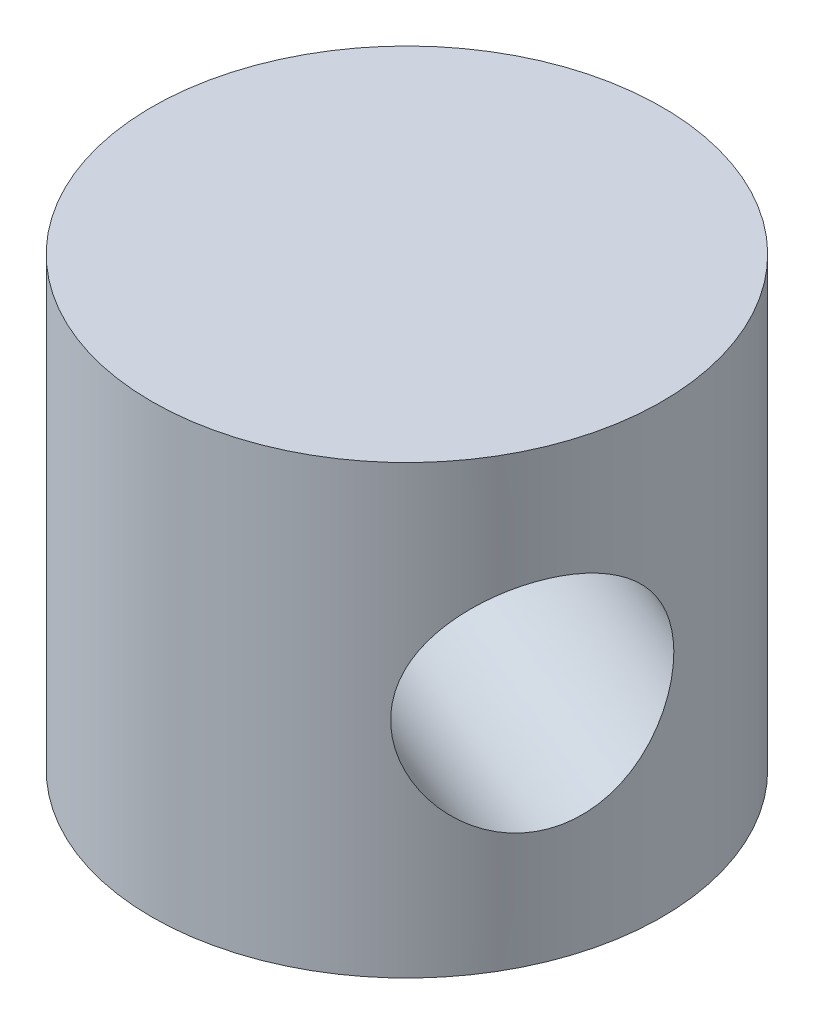
from build123d import *

# Parameters (mm, degrees)
SKETCH1_R           = 8
BOSS_EXTRUDE1_DEPTH = 14
M8_TAPPED_HOLE1_D   = 6.8


with BuildPart() as part:
    # Sketch1 → Boss-Extrude1 (new body)
    with BuildSketch(Plane(origin=(0, 0, 0), x_dir=(1, 0, 0), z_dir=(0, 1, 0))):
        Circle(SKETCH1_R)
    extrude(amount=BOSS_EXTRUDE1_DEPTH)

    # M8 Tapped Hole1 (through all)
    with Locations(Plane(origin=(7.394049334, 7, 3.054183107), x_dir=(-0.381772888, 0, 0.924256167), z_dir=(0.924256167, 0, 0.381772888))):
        with Locations((0, 0)):
            Hole(M8_TAPPED_HOLE1_D / 2)


solid = part.part
